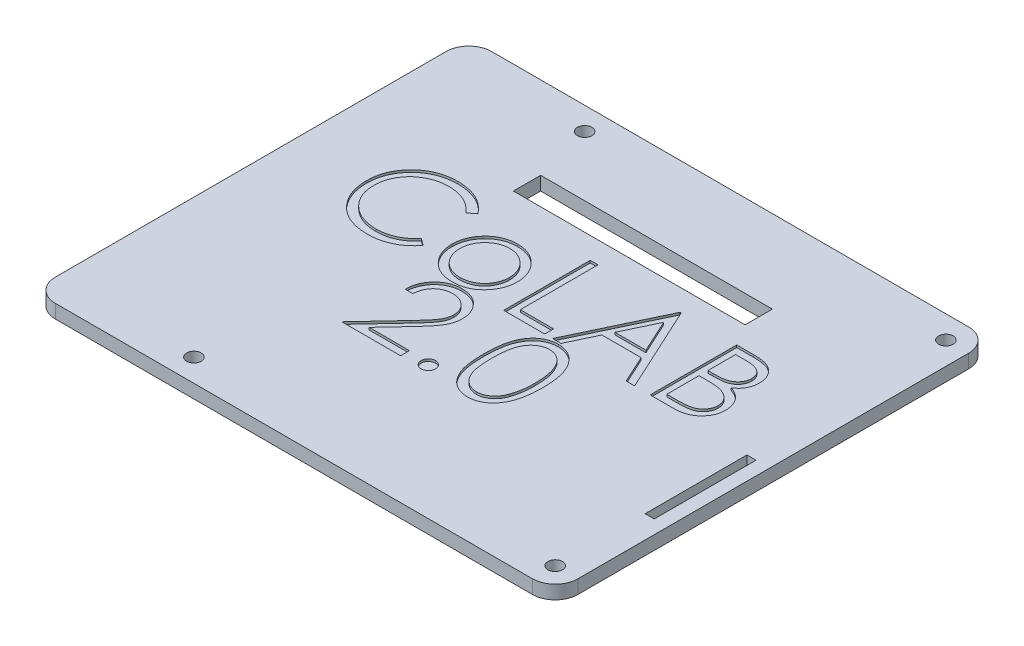
from build123d import *

# Parameters (mm, degrees)
BOSS_EXTRUDE1_DEPTH     = 3
CUT_EXTRUDE1_DEPTH      = 0.5
SKETCH3_R               = 1.6
CUT_EXTRUDE2_DEPTH      = 1
CUT_EXTRUDE2_DEPTH_BACK = 4.0000001
SKETCH5_W               = 2
SKETCH5_H               = 22.4
CUT_EXTRUDE3_DEPTH      = 1.0000001
CUT_EXTRUDE3_DEPTH_BACK = 4
SKETCH6_R               = 3.5
SKETCH6_R_2             = 1.45
BOSS_EXTRUDE2_DEPTH     = 5
SKETCH7_W               = 51
SKETCH7_H               = 6
CUT_EXTRUDE4_DEPTH      = 1.0000001
CUT_EXTRUDE4_DEPTH_BACK = 9


with BuildPart() as part:
    # Sketch1 → Boss-Extrude1 (new body)
    with BuildSketch(Plane(origin=(0, 0, 0), x_dir=(1, 0, 0), z_dir=(0, 1, 0))):
        with BuildLine():
            Line((5, 0), (110, 0))
            ThreePointArc((110, 0), (113.535533906, 1.464466094), (115, 5))
            Line((115, 5), (115, 91))
            ThreePointArc((115, 91), (113.535533906, 94.535533906), (110, 96))
            Line((110, 96), (5, 96))
            ThreePointArc((5, 96), (1.464466094, 94.535533906), (0, 91))
            Line((0, 91), (0, 5))
            ThreePointArc((0, 5), (1.464466094, 1.464466094), (5, 0))
        make_face()
    extrude(amount=BOSS_EXTRUDE1_DEPTH)

    # Sketch2 → Cut-Extrude1 (cut)
    with BuildSketch(Plane(origin=(0, 3, 0), x_dir=(1, 0, 0), z_dir=(0, 1, 0))):
        with BuildLine():
            Line((34.420192308, 63.554447115), (32.924278846, 62.409615385))
            add(Edge.make_bspline(
                [(32.924278846, 62.409615385), (32.817566797, 62.53679302), (32.605581408, 62.789433662), (32.26453632, 63.144196611), (31.909108806, 63.476566105), (31.539434732, 63.788125479), (31.148860096, 64.067979589), (30.74684632, 64.330712307), (30.326668389, 64.566212423), (29.745633947, 64.851760962), (28.985550659, 65.149736463), (28.028724463, 65.399581193), (27.02989977, 65.558627878), (26.348467121, 65.575853658), (26.001862981, 65.584615385)],
                knots=[0, 0, 0, 0, 0.00049794, 0.000989166, 0.001475147, 0.001957397, 0.002438287, 0.002915667, 0.003397525, 0.003882215, 0.004857325, 0.005840349, 0.006844209, 0.007883375, 0.007883375, 0.007883375, 0.007883375], degree=3))
            add(Edge.make_bspline(
                [(26.001862981, 65.584615385), (25.810909594, 65.582416674), (25.430775049, 65.57803966), (24.866631215, 65.520295707), (24.313021608, 65.439136121), (23.770306342, 65.318711147), (23.239176239, 65.166460178), (22.716159022, 64.984530425), (22.208827043, 64.759441939), (21.710162061, 64.51065841), (21.232392355, 64.229657604), (20.780335595, 63.923152074), (20.355640513, 63.594571707), (19.957971152, 63.24268497), (19.586920976, 62.869076586), (19.245178613, 62.469764955), (18.933926594, 62.046026696), (18.646995358, 61.603449435), (18.390023195, 61.143322312), (18.174867709, 60.663942286), (17.984339829, 60.173518525), (17.833576809, 59.666510064), (17.714244796, 59.146484438), (17.631907085, 58.612046007), (17.574819835, 58.064311265), (17.570464586, 57.693057721), (17.568269231, 57.505919471)],
                knots=[0, 0, 0, 0, 0.000572619, 0.001139924, 0.001699592, 0.002250514, 0.002806148, 0.003356514, 0.003910218, 0.00446999, 0.005027612, 0.005571644, 0.006107491, 0.006637367, 0.007163561, 0.007685922, 0.008212558, 0.008739692, 0.009267502, 0.009791769, 0.010314798, 0.010844798, 0.0113771, 0.011914141, 0.012466252, 0.013027427, 0.013027427, 0.013027427, 0.013027427], degree=3))
            add(Edge.make_bspline(
                [(17.568269231, 57.505919471), (17.575137131, 57.224353287), (17.588621343, 56.671535432), (17.708627276, 55.861798252), (17.890990702, 55.086078585), (18.164306913, 54.349225443), (18.50132346, 53.642152809), (18.927175931, 52.976824192), (19.420388799, 52.343185462), (19.987939567, 51.756211704), (20.61063408, 51.220015571), (21.278733428, 50.747844548), (21.990573622, 50.354244974), (22.738294995, 50.026715893), (23.527651415, 49.774947133), (24.357223411, 49.597705261), (25.2252067, 49.482087107), (25.818311576, 49.471018033), (26.12016226, 49.465384615)],
                knots=[0, 0, 0, 0, 0.000844222, 0.001657519, 0.002450727, 0.003230596, 0.004010586, 0.004796148, 0.005595401, 0.006415872, 0.007241219, 0.008057492, 0.008865515, 0.009677279, 0.010502758, 0.011346325, 0.012219621, 0.01312469, 0.01312469, 0.01312469, 0.01312469], degree=3))
            add(Edge.make_bspline(
                [(26.12016226, 49.465384615), (26.452735467, 49.474576402), (27.107319097, 49.492668038), (28.067265069, 49.645934808), (28.986214022, 49.894444332), (29.864215386, 50.242231595), (30.69879396, 50.694344091), (31.491255782, 51.242428252), (32.242269759, 51.891697606), (32.693870595, 52.387450061), (32.924278846, 52.640384615)],
                knots=[0, 0, 0, 0, 0.000997238, 0.001962804, 0.002907981, 0.00384834, 0.004789132, 0.005749229, 0.006733947, 0.007759692, 0.007759692, 0.007759692, 0.007759692], degree=3))
            Line((32.924278846, 52.640384615), (34.420192308, 51.507001202))
            add(Edge.make_bspline(
                [(34.420192308, 51.507001202), (34.299806595, 51.351670485), (34.059611811, 51.041753077), (33.670676033, 50.604845628), (33.260952457, 50.193887949), (32.827397807, 49.812193325), (32.374999542, 49.452124019), (31.895634527, 49.123909766), (31.395604507, 48.822969382), (30.876603701, 48.547414264), (30.339183537, 48.302936105), (29.78398797, 48.093637741), (29.213410123, 47.913343699), (28.627423913, 47.7650153), (28.024813865, 47.64923983), (27.40775457, 47.571844171), (26.774914249, 47.518820322), (26.3479688, 47.513987523), (26.131610577, 47.511538462)],
                knots=[0, 0, 0, 0, 0.000589425, 0.001176026, 0.001753482, 0.00232931, 0.002908013, 0.003487018, 0.004070795, 0.004658029, 0.005248935, 0.005840739, 0.006436956, 0.007043188, 0.007653157, 0.008276538, 0.008908147, 0.009557065, 0.009557065, 0.009557065, 0.009557065], degree=3))
            add(Edge.make_bspline(
                [(26.131610577, 47.511538462), (25.926721475, 47.51296445), (25.521578647, 47.515784164), (24.923415442, 47.561461533), (24.341086438, 47.623780815), (23.776255974, 47.717616386), (23.225841739, 47.828347722), (22.694833415, 47.976781276), (22.17800577, 48.143056026), (21.67743523, 48.338481739), (21.192696006, 48.559005533), (20.725351547, 48.808242446), (20.275616794, 49.084096595), (19.839070146, 49.380487438), (19.422160441, 49.706935324), (19.021274824, 50.058906577), (18.634165346, 50.435214893), (18.394665018, 50.706567737), (18.274248798, 50.842998798)],
                knots=[0, 0, 0, 0, 0.0006145, 0.001215097, 0.001798762, 0.002370923, 0.002932241, 0.003482144, 0.004023991, 0.004560449, 0.005093244, 0.005620764, 0.006148271, 0.006675391, 0.00720287, 0.00773561, 0.008275316, 0.008821059, 0.008821059, 0.008821059, 0.008821059], degree=3))
            add(Edge.make_bspline(
                [(18.274248798, 50.842998798), (18.081377653, 51.079987269), (17.697963872, 51.551103079), (17.207422651, 52.314659634), (16.787519529, 53.111865171), (16.448016303, 53.946907926), (16.182607713, 54.817914134), (15.998741494, 55.725322862), (15.879262047, 56.668286662), (15.865598904, 57.309655469), (15.858653846, 57.635667067)],
                knots=[0, 0, 0, 0, 0.000916064, 0.001821069, 0.002717204, 0.003615773, 0.004521164, 0.005444709, 0.006390426, 0.007368094, 0.007368094, 0.007368094, 0.007368094], degree=3))
            add(Edge.make_bspline(
                [(15.858653846, 57.635667067), (15.867118543, 57.978324607), (15.883772304, 58.652481925), (16.025263705, 59.641851585), (16.252877439, 60.589732771), (16.576166218, 61.494356009), (16.986042487, 62.360479391), (17.492373057, 63.181486521), (18.089275645, 63.962627959), (18.772068835, 64.692051105), (19.520828189, 65.359015296), (20.322663447, 65.945789062), (21.176005187, 66.434108685), (22.071452351, 66.842302083), (23.015710132, 67.156052661), (24.006763899, 67.375689291), (25.04275142, 67.512398167), (25.749574052, 67.52968037), (26.108713942, 67.538461538)],
                knots=[0, 0, 0, 0, 0.001027553, 0.002021647, 0.002991636, 0.003947584, 0.004898354, 0.00586111, 0.006835779, 0.007842891, 0.008853835, 0.009840024, 0.01081793, 0.011798246, 0.012787788, 0.013796915, 0.014839669, 0.015916785, 0.015916785, 0.015916785, 0.015916785], degree=3))
            add(Edge.make_bspline(
                [(26.108713942, 67.538461538), (26.327595568, 67.535837329), (26.760849703, 67.530642971), (27.401760569, 67.479990969), (28.025742377, 67.395552627), (28.633225008, 67.280620875), (29.227163819, 67.137978168), (29.803019415, 66.952157402), (30.36417084, 66.739687138), (30.907079011, 66.494984631), (31.429139091, 66.220301367), (31.930188482, 65.918682045), (32.406247213, 65.590500589), (32.860665088, 65.238548163), (33.285840466, 64.855378861), (33.693845084, 64.451531946), (34.070823238, 64.015374989), (34.303522771, 63.708370992), (34.420192308, 63.554447115)],
                knots=[0, 0, 0, 0, 0.000656548, 0.00129957, 0.001927235, 0.002544702, 0.003153715, 0.00375836, 0.004358654, 0.004953036, 0.005543646, 0.006127422, 0.006706428, 0.007277417, 0.007850392, 0.008422452, 0.008998633, 0.009577991, 0.009577991, 0.009577991, 0.009577991], degree=3))
        make_face()
        with BuildLine():
            add(Edge.make_bspline(
                [(44.563401442, 62.165384615), (44.824611084, 62.159822608), (45.336779356, 62.148916871), (46.086847992, 62.032358272), (46.802829375, 61.854119046), (47.48746565, 61.607712401), (48.131988629, 61.277429213), (48.745786401, 60.883315785), (49.32717612, 60.416413383), (49.675644323, 60.055235897), (49.852524038, 59.871905048)],
                knots=[0, 0, 0, 0, 0.000783055, 0.00153538, 0.002271186, 0.002994326, 0.003712818, 0.004438972, 0.005179778, 0.005943429, 0.005943429, 0.005943429, 0.005943429], degree=3))
            add(Edge.make_bspline(
                [(49.852524038, 59.871905048), (50.004825817, 59.696568925), (50.306481915, 59.349289917), (50.69328247, 58.786195795), (51.026502676, 58.203047533), (51.293545364, 57.59210137), (51.504102421, 56.958690659), (51.653594282, 56.300638284), (51.742513886, 55.619397509), (51.75450432, 55.156733762), (51.760576923, 54.922415865)],
                knots=[0, 0, 0, 0, 0.000696259, 0.001379043, 0.002045498, 0.002708457, 0.003375796, 0.004045107, 0.00473002, 0.005432847, 0.005432847, 0.005432847, 0.005432847], degree=3))
            add(Edge.make_bspline(
                [(51.760576923, 54.922415865), (51.755235644, 54.686739837), (51.744681028, 54.221033014), (51.644839345, 53.535127609), (51.48954872, 52.870038646), (51.267306858, 52.228550613), (50.982329149, 51.608702652), (50.634581264, 51.013202105), (50.221622891, 50.440874065), (49.753515423, 49.896578346), (49.23616164, 49.394930805), (48.674915175, 48.95771551), (48.080805363, 48.583129784), (47.445932254, 48.281397293), (46.776093505, 48.043491639), (46.06984432, 47.876395835), (45.328281865, 47.775367242), (44.821947989, 47.762393793), (44.563401442, 47.755769231)],
                knots=[0, 0, 0, 0, 0.000706639, 0.001396352, 0.002074825, 0.002753062, 0.003429246, 0.004118441, 0.004818465, 0.005543646, 0.006269639, 0.006976516, 0.007674289, 0.008372397, 0.009080888, 0.009802849, 0.01054601, 0.011321441, 0.011321441, 0.011321441, 0.011321441], degree=3))
            add(Edge.make_bspline(
                [(44.563401442, 47.755769231), (44.303588183, 47.762416027), (43.79473079, 47.775434114), (43.050550802, 47.876003324), (42.343035876, 48.04341463), (41.672320219, 48.282179126), (41.034717552, 48.583139428), (40.437165333, 48.956583053), (39.875462935, 49.395060469), (39.357999706, 49.896543212), (38.889921583, 50.440883117), (38.476955637, 51.013199756), (38.129209719, 51.608703264), (37.844231495, 52.228550449), (37.62198977, 52.870038689), (37.466699109, 53.535127597), (37.366857435, 54.221033017), (37.356302818, 54.686739838), (37.350961538, 54.922415865)],
                knots=[0, 0, 0, 0, 0.000779243, 0.001526186, 0.002248147, 0.002956639, 0.00365819, 0.004359201, 0.005066078, 0.005792071, 0.006517252, 0.007217276, 0.007906471, 0.008582655, 0.009260891, 0.009939365, 0.010629078, 0.011335717, 0.011335717, 0.011335717, 0.011335717], degree=3))
            add(Edge.make_bspline(
                [(37.350961538, 54.922415865), (37.357075556, 55.155460208), (37.369180261, 55.616847955), (37.45801046, 56.2968081), (37.606919175, 56.953746746), (37.817728633, 57.584712551), (38.087232743, 58.192981424), (38.41577061, 58.777570576), (38.806516767, 59.338118461), (39.106973103, 59.68494864), (39.259014423, 59.860456731)],
                knots=[0, 0, 0, 0, 0.000699014, 0.001383928, 0.002053239, 0.002716956, 0.003376425, 0.004046203, 0.004725856, 0.005422115, 0.005422115, 0.005422115, 0.005422115], degree=3))
            add(Edge.make_bspline(
                [(39.259014423, 59.860456731), (39.435627469, 60.045377472), (39.782968099, 60.409056647), (40.367251888, 60.874597956), (40.979539686, 61.276912587), (41.631185356, 61.600633131), (42.315259197, 61.855568492), (43.034909645, 62.032817938), (43.787523522, 62.148496913), (44.302198031, 62.159699281), (44.563401442, 62.165384615)],
                knots=[0, 0, 0, 0, 0.000766344, 0.00150715, 0.002235377, 0.002960688, 0.003685145, 0.004420951, 0.005180826, 0.005963881, 0.005963881, 0.005963881, 0.005963881], degree=3))
        make_face()
        with BuildLine():
            add(Edge.make_bspline(
                [(44.555769231, 60.455769231), (44.371051661, 60.450519096), (44.006384975, 60.440154358), (43.469612663, 60.361320534), (42.952866969, 60.236420547), (42.455167517, 60.058961327), (41.978192678, 59.829823034), (41.521485788, 59.548381817), (41.083703508, 59.218365296), (40.673409706, 58.840289898), (40.296860264, 58.427291371), (39.967687277, 57.987245303), (39.68778777, 57.527289333), (39.454614905, 57.046945155), (39.280948638, 56.541345016), (39.154821187, 56.016214723), (39.076061735, 55.470484385), (39.065794446, 55.0994937), (39.060576923, 54.910967548)],
                knots=[0, 0, 0, 0, 0.00055398, 0.001093659, 0.001624001, 0.002146641, 0.00267576, 0.003208513, 0.003753455, 0.004317942, 0.004879857, 0.00542785, 0.00596386, 0.006492979, 0.007026416, 0.007564175, 0.008111411, 0.008676826, 0.008676826, 0.008676826, 0.008676826], degree=3))
            add(Edge.make_bspline(
                [(39.060576923, 54.910967548), (39.069322635, 54.667388657), (39.086681237, 54.183930107), (39.227843023, 53.471943854), (39.463988347, 52.788419773), (39.782870541, 52.137364872), (40.182410102, 51.534991473), (40.653146851, 50.99793668), (41.190028649, 50.534282477), (41.7866556, 50.149576732), (42.430841244, 49.843907205), (43.112593506, 49.627287066), (43.823652141, 49.48647114), (44.309594406, 49.472474972), (44.555769231, 49.465384615)],
                knots=[0, 0, 0, 0, 0.000730313, 0.001449535, 0.002167582, 0.002894618, 0.003618562, 0.004329721, 0.005030483, 0.005739673, 0.006453204, 0.007162815, 0.007881317, 0.008619021, 0.008619021, 0.008619021, 0.008619021], degree=3))
            add(Edge.make_bspline(
                [(44.555769231, 49.465384615), (44.801929896, 49.472516284), (45.287844211, 49.486593999), (45.997914874, 49.62657786), (46.677803778, 49.844856357), (47.32132033, 50.149232956), (47.9176757, 50.535743385), (48.458418775, 50.995318523), (48.925136215, 51.536413914), (49.32428055, 52.138162749), (49.648384964, 52.787410437), (49.883424963, 53.472070008), (50.024926109, 54.183897979), (50.042238905, 54.667377893), (50.050961538, 54.910967548)],
                knots=[0, 0, 0, 0, 0.000737704, 0.001456207, 0.002162186, 0.002875716, 0.003584906, 0.004288562, 0.004997207, 0.005721152, 0.006449878, 0.007167925, 0.007887147, 0.00861746, 0.00861746, 0.00861746, 0.00861746], degree=3))
            add(Edge.make_bspline(
                [(50.050961538, 54.910967548), (50.045745812, 55.099494826), (50.035482057, 55.470487729), (49.956696894, 56.016201941), (49.8306646, 56.541391917), (49.656647654, 57.046772106), (49.42448795, 57.528533022), (49.139190834, 57.985894822), (48.811361967, 58.428815737), (48.43026878, 58.838954839), (48.020403252, 59.218512681), (47.582443544, 59.548509786), (47.126413875, 59.828586128), (46.650824732, 60.060921237), (46.153061471, 60.234806047), (45.637039811, 60.362041712), (45.102557717, 60.439821211), (44.739197782, 60.450419224), (44.555769231, 60.455769231)],
                knots=[0, 0, 0, 0, 0.000565415, 0.00111265, 0.00165041, 0.002183846, 0.002712966, 0.003250969, 0.003798962, 0.004363449, 0.004927936, 0.005472878, 0.006005632, 0.006531314, 0.007057549, 0.007584185, 0.008123864, 0.008674032, 0.008674032, 0.008674032, 0.008674032], degree=3))
        make_face(mode=Mode.SUBTRACT)
        Polygon((55.668269231, 67.05), (57.377884615, 67.05), (57.377884615, 49.953846154), (64.704807692, 49.953846154), (64.704807692, 48), (55.668269231, 48), align=None)
        Polygon((75.695192308, 67.05), (84.4875, 48), (82.62905649, 48), (79.812770433, 54.105769231), (71.176923077, 54.105769231), (68.280498798, 48), (66.414423077, 48), (75.450961538, 67.05), align=None)
        Polygon((75.553996394, 63.336929087), (72.104236779, 56.059615385), (78.912169471, 56.059615385), align=None, mode=Mode.SUBTRACT)
        with BuildLine():
            Line((87.906730769, 67.05), (91.623617788, 67.05))
            add(Edge.make_bspline(
                [(91.623617788, 67.05), (91.80556422, 67.049043416), (92.158221686, 67.047189317), (92.671044648, 67.018433989), (93.151370317, 66.979225443), (93.599337993, 66.917013082), (94.014740673, 66.841946409), (94.398830241, 66.75104081), (94.750385322, 66.642038813), (95.17009893, 66.468704053), (95.648638527, 66.211130809), (96.166789778, 65.830519618), (96.609861424, 65.36497864), (96.991875522, 64.83983733), (97.295593045, 64.262155487), (97.515317363, 63.645701902), (97.654425227, 62.99842785), (97.668731419, 62.554055696), (97.675961538, 62.329477163)],
                knots=[0, 0, 0, 0, 0.000545756, 0.001057812, 0.00154047, 0.00199111, 0.00241401, 0.002806457, 0.003174568, 0.003516849, 0.004167392, 0.004800106, 0.005437019, 0.006087371, 0.006742853, 0.007387425, 0.008046032, 0.008718977, 0.008718977, 0.008718977, 0.008718977], degree=3))
            add(Edge.make_bspline(
                [(97.675961538, 62.329477163), (97.670011307, 62.119096825), (97.65831854, 61.705679619), (97.546507236, 61.101010253), (97.371461312, 60.525421476), (97.128137027, 59.981013921), (96.811896162, 59.480088113), (96.43711017, 59.018603136), (95.984935003, 58.616098097), (95.646153939, 58.391074585), (95.47406851, 58.276772837)],
                knots=[0, 0, 0, 0, 0.000630593, 0.001239176, 0.001837903, 0.002432285, 0.003022056, 0.003610343, 0.004210261, 0.004829576, 0.004829576, 0.004829576, 0.004829576], degree=3))
            add(Edge.make_bspline(
                [(95.47406851, 58.276772837), (95.690478837, 58.193687628), (96.104525402, 58.034725042), (96.674316412, 57.753680588), (97.165234069, 57.447998245), (97.581052821, 57.114177746), (97.936676342, 56.754356933), (98.247207353, 56.363259811), (98.512173118, 55.935784572), (98.739210602, 55.476388187), (98.916368831, 54.989761552), (99.049043396, 54.480469185), (99.125066227, 53.95033732), (99.135884674, 53.589555469), (99.141346154, 53.407421875)],
                knots=[0, 0, 0, 0, 0.00069517, 0.001330033, 0.001902818, 0.002426682, 0.002925892, 0.003417578, 0.003921593, 0.004431882, 0.004952231, 0.005472399, 0.0060083, 0.006554657, 0.006554657, 0.006554657, 0.006554657], degree=3))
            add(Edge.make_bspline(
                [(99.141346154, 53.407421875), (99.13602932, 53.221456471), (99.125568302, 52.855564329), (99.048388741, 52.318054239), (98.917710602, 51.804384887), (98.737709076, 51.311233821), (98.502782764, 50.839555089), (98.216880558, 50.388814324), (97.875985905, 49.963540324), (97.494643718, 49.559007461), (97.063231183, 49.195273362), (96.597781146, 48.871337873), (96.09243189, 48.604931449), (95.55548318, 48.381142817), (94.980911688, 48.210197923), (94.371297497, 48.090604342), (93.727166368, 48.010022641), (93.285153294, 48.003397568), (93.058473558, 48)],
                knots=[0, 0, 0, 0, 0.000557791, 0.00109747, 0.001625032, 0.002145382, 0.002669315, 0.003202874, 0.00374343, 0.00430216, 0.004867987, 0.005433235, 0.006000039, 0.006578327, 0.007175946, 0.007794874, 0.008440506, 0.009120159, 0.009120159, 0.009120159, 0.009120159], degree=3))
            Line((93.058473558, 48), (87.906730769, 48))
            Line((87.906730769, 48), (87.906730769, 67.05))
        make_face()
        with BuildLine():
            Line((89.616346154, 65.096153846), (89.616346154, 58.990384615))
            Line((89.616346154, 58.990384615), (90.76499399, 58.990384615))
            add(Edge.make_bspline(
                [(90.76499399, 58.990384615), (90.932899577, 58.992561339), (91.257327386, 58.996767213), (91.727154252, 59.00881507), (92.163263279, 59.042550135), (92.564901685, 59.076275504), (92.931436987, 59.131110046), (93.262057148, 59.196381458), (93.56195094, 59.265412698), (93.907787609, 59.382812334), (94.300070371, 59.556317966), (94.718261981, 59.825586103), (95.086931023, 60.146302939), (95.398247144, 60.516368031), (95.653035291, 60.923853986), (95.830002798, 61.362259149), (95.950003016, 61.820657296), (95.960842637, 62.135353787), (95.966346154, 62.295132212)],
                knots=[0, 0, 0, 0, 0.000503784, 0.000973413, 0.001409519, 0.001815822, 0.002182268, 0.002520548, 0.002826908, 0.003104462, 0.003615151, 0.004109495, 0.004590899, 0.005075605, 0.005555358, 0.006025916, 0.006489616, 0.006967864, 0.006967864, 0.006967864, 0.006967864], degree=3))
            add(Edge.make_bspline(
                [(95.966346154, 62.295132212), (95.96348223, 62.400863911), (95.957864331, 62.608268185), (95.911854213, 62.910615384), (95.833653558, 63.194970665), (95.733209476, 63.465230894), (95.592845327, 63.712945393), (95.427581334, 63.946679073), (95.227906363, 64.158472175), (95.000627275, 64.356426159), (94.7393232, 64.531928517), (94.444150026, 64.685638957), (94.11111424, 64.809413755), (93.745828558, 64.917814528), (93.342670211, 64.993950813), (92.90629157, 65.057378537), (92.433118314, 65.089669604), (92.105757113, 65.093944222), (91.936538462, 65.096153846)],
                knots=[0, 0, 0, 0, 0.000317104, 0.000622035, 0.000914559, 0.001200868, 0.001484418, 0.001766113, 0.002057739, 0.002355347, 0.002668639, 0.002999762, 0.003351279, 0.00373289, 0.004141516, 0.004580816, 0.005055258, 0.005562929, 0.005562929, 0.005562929, 0.005562929], degree=3))
            Line((91.936538462, 65.096153846), (89.616346154, 65.096153846))
        make_face(mode=Mode.SUBTRACT)
        with BuildLine():
            Line((89.616346154, 57.036538462), (89.616346154, 49.953846154))
            Line((89.616346154, 49.953846154), (92.051021635, 49.953846154))
            add(Edge.make_bspline(
                [(92.051021635, 49.953846154), (92.225296074, 49.955934836), (92.561187082, 49.959960496), (93.046152348, 49.973102571), (93.495640385, 50.002996243), (93.907600095, 50.050054368), (94.286479844, 50.101099927), (94.627734485, 50.169741327), (94.934130295, 50.248384955), (95.289409027, 50.369946664), (95.689478122, 50.558794599), (96.120611498, 50.84353346), (96.503931342, 51.182750321), (96.829442825, 51.575348582), (97.096213519, 52.00223909), (97.290281068, 52.454787352), (97.409974159, 52.925515723), (97.424463967, 53.246463115), (97.431730769, 53.407421875)],
                knots=[0, 0, 0, 0, 0.000522862, 0.001007748, 0.001455275, 0.001873744, 0.002251519, 0.00260177, 0.002917401, 0.003199793, 0.003727272, 0.004239541, 0.004745013, 0.005257068, 0.005764323, 0.006249869, 0.006729304, 0.007211645, 0.007211645, 0.007211645, 0.007211645], degree=3))
            add(Edge.make_bspline(
                [(97.431730769, 53.407421875), (97.430227973, 53.508078486), (97.42724662, 53.707768106), (97.382285273, 54.001224208), (97.316895496, 54.285482176), (97.23236012, 54.561313877), (97.109245592, 54.823732397), (96.96551854, 55.077927757), (96.797000054, 55.324235981), (96.534413951, 55.635634103), (96.152477864, 55.994410988), (95.609788129, 56.345679393), (94.992718907, 56.628968171), (94.54516641, 56.749252464), (94.313972356, 56.811388221)],
                knots=[0, 0, 0, 0, 0.00030169, 0.000598513, 0.000888261, 0.001176699, 0.001461887, 0.001755827, 0.002052208, 0.00235563, 0.002976636, 0.003615922, 0.004287047, 0.005004191, 0.005004191, 0.005004191, 0.005004191], degree=3))
            add(Edge.make_bspline(
                [(94.313972356, 56.811388221), (94.22128542, 56.83019375), (94.020321024, 56.870968014), (93.692619765, 56.914008514), (93.31850025, 56.952353768), (92.89709859, 56.980717355), (92.427881626, 57.010035542), (91.909847254, 57.021437354), (91.345111013, 57.03504047), (90.953266815, 57.036026358), (90.749729567, 57.036538462)],
                knots=[0, 0, 0, 0, 0.000283652, 0.000615017, 0.000990937, 0.001411818, 0.001881958, 0.002401173, 0.002966073, 0.003576662, 0.003576662, 0.003576662, 0.003576662], degree=3))
            Line((90.749729567, 57.036538462), (89.616346154, 57.036538462))
        make_face(mode=Mode.SUBTRACT)
        with BuildLine():
            Line((42.479807692, 41.188461538), (40.770192308, 41.188461538))
            add(Edge.make_bspline(
                [(40.770192308, 41.188461538), (40.781334669, 41.415270228), (40.80321797, 41.860716457), (40.905697659, 42.510179433), (41.052333005, 43.130963409), (41.259659347, 43.718083941), (41.517140659, 44.276732306), (41.825914094, 44.804689534), (42.191640623, 45.299941576), (42.60642299, 45.75789728), (43.056920868, 46.178018201), (43.543000339, 46.540813165), (44.053785416, 46.847342205), (44.58772643, 47.103598679), (45.150847498, 47.295948411), (45.738038481, 47.43866905), (46.351879209, 47.524537446), (46.770108472, 47.533767365), (46.9828125, 47.538461538)],
                knots=[0, 0, 0, 0, 0.000680809, 0.00133709, 0.001969252, 0.002592014, 0.003201565, 0.003812201, 0.004423565, 0.00504504, 0.005663449, 0.006268684, 0.006860967, 0.007448164, 0.008041934, 0.008642628, 0.00925895, 0.009896799, 0.009896799, 0.009896799, 0.009896799], degree=3))
            add(Edge.make_bspline(
                [(46.9828125, 47.538461538), (47.191698875, 47.533571368), (47.602153139, 47.523962359), (48.201204961, 47.441443042), (48.771492806, 47.312199179), (49.311901935, 47.130868128), (49.818120658, 46.887112887), (50.293951801, 46.59430057), (50.745060214, 46.255646916), (51.151134279, 45.856936874), (51.524013967, 45.431292467), (51.845699099, 44.976879735), (52.121179317, 44.507546051), (52.350800832, 44.019712554), (52.51983496, 43.508785956), (52.648167778, 42.982204753), (52.720706987, 42.434518281), (52.731839934, 42.063824029), (52.7375, 41.875360577)],
                knots=[0, 0, 0, 0, 0.000626411, 0.001230876, 0.001810371, 0.002378766, 0.002936923, 0.003491927, 0.004052907, 0.004625069, 0.005195867, 0.00574861, 0.006292495, 0.006826886, 0.007362692, 0.007904163, 0.008450879, 0.009016294, 0.009016294, 0.009016294, 0.009016294], degree=3))
            add(Edge.make_bspline(
                [(52.7375, 41.875360577), (52.728283812, 41.610033077), (52.710013168, 41.0840342), (52.553724918, 40.31106759), (52.309631765, 39.562166266), (52.015731865, 38.95943895), (51.719246134, 38.473753792), (51.452069843, 38.073874126), (51.139297086, 37.643314363), (50.776375547, 37.183516283), (50.370812628, 36.690878357), (49.918934853, 36.165698185), (49.417519901, 35.613401838), (49.065592919, 35.23618135), (48.883233173, 35.040715144)],
                knots=[0, 0, 0, 0, 0.000795299, 0.001576641, 0.002356211, 0.003153266, 0.003581282, 0.004062853, 0.004595648, 0.00517735, 0.005819874, 0.006509872, 0.007255587, 0.008057559, 0.008057559, 0.008057559, 0.008057559], degree=3))
            Line((48.883233173, 35.040715144), (44.116917067, 29.953846154))
            Line((44.116917067, 29.953846154), (52.981730769, 29.953846154))
            Line((52.981730769, 29.953846154), (52.981730769, 28))
            Line((52.981730769, 28), (40.0375, 28))
            Line((40.0375, 28), (47.425480769, 35.884074519))
            add(Edge.make_bspline(
                [(47.425480769, 35.884074519), (47.605355696, 36.071843873), (47.950858618, 36.432510375), (48.439532357, 36.959068486), (48.878438851, 37.447562415), (49.270419232, 37.8970692), (49.606970168, 38.314163877), (49.905631888, 38.685337906), (50.144930318, 39.026901414), (50.404638401, 39.422818184), (50.656174499, 39.906210939), (50.87232318, 40.496944305), (51.004121141, 41.10505978), (51.019931746, 41.516006582), (51.027884615, 41.722716346)],
                knots=[0, 0, 0, 0, 0.000780065, 0.001498345, 0.002154992, 0.002750207, 0.003287207, 0.003762814, 0.004178927, 0.004537763, 0.005182945, 0.005808274, 0.006420494, 0.007040127, 0.007040127, 0.007040127, 0.007040127], degree=3))
            add(Edge.make_bspline(
                [(51.027884615, 41.722716346), (51.024424361, 41.852699386), (51.017604864, 42.108870997), (50.957419396, 42.484459486), (50.866466498, 42.846762258), (50.73613588, 43.196893742), (50.564104909, 43.531333648), (50.354699798, 43.850489076), (50.113091024, 44.159039015), (49.833593401, 44.448344823), (49.526553558, 44.71330967), (49.202190571, 44.948027907), (48.85901786, 45.144183638), (48.498482338, 45.304984673), (48.12158914, 45.431124962), (47.727609313, 45.518529516), (47.317631453, 45.573407036), (47.037686284, 45.580832028), (46.895042067, 45.584615385)],
                knots=[0, 0, 0, 0, 0.00038971, 0.000768044, 0.001138265, 0.001508978, 0.001886155, 0.002264027, 0.002652614, 0.003060152, 0.003468689, 0.003867942, 0.004259386, 0.004652278, 0.005050509, 0.005449524, 0.005861328, 0.006289158, 0.006289158, 0.006289158, 0.006289158], degree=3))
            add(Edge.make_bspline(
                [(46.895042067, 45.584615385), (46.746066535, 45.580723566), (46.453503187, 45.573080677), (46.023958165, 45.51961732), (45.614188433, 45.427383532), (45.223163218, 45.301236204), (44.850220901, 45.140897531), (44.497175176, 44.941189607), (44.164818593, 44.702882308), (43.852526373, 44.432695852), (43.564795287, 44.131882194), (43.311991577, 43.796547966), (43.091098585, 43.432815891), (42.898371186, 43.041667409), (42.741858073, 42.619553263), (42.622261354, 42.167971898), (42.527627231, 41.688884094), (42.496012283, 41.35803956), (42.479807692, 41.188461538)],
                knots=[0, 0, 0, 0, 0.000446892, 0.000877622, 0.001296091, 0.001705198, 0.002108569, 0.002511851, 0.002919531, 0.003333451, 0.003749144, 0.004165869, 0.004590624, 0.005024118, 0.0054721, 0.005938665, 0.006424391, 0.006935151, 0.006935151, 0.006935151, 0.006935151], degree=3))
        make_face()
        with BuildLine():
            add(Edge.make_bspline(
                [(57.744230769, 30.930769231), (57.85031321, 30.924465495), (58.058275433, 30.912107758), (58.358934117, 30.827326148), (58.631047907, 30.67678401), (58.873430554, 30.476145174), (59.073218662, 30.232873064), (59.229125779, 29.962929618), (59.313168855, 29.659753807), (59.325436575, 29.450586576), (59.331730769, 29.343269231)],
                knots=[0, 0, 0, 0, 0.000318205, 0.000623803, 0.000927753, 0.001244857, 0.001561962, 0.001867751, 0.002173349, 0.002495352, 0.002495352, 0.002495352, 0.002495352], degree=3))
            add(Edge.make_bspline(
                [(59.331730769, 29.343269231), (59.325223285, 29.238530536), (59.312390622, 29.031987368), (59.229318427, 28.731098264), (59.072030467, 28.460986113), (58.874808577, 28.214413047), (58.630987989, 28.013349165), (58.358290796, 27.864087817), (58.058981234, 27.773235755), (57.85043096, 27.761662624), (57.744230769, 27.755769231)],
                knots=[0, 0, 0, 0, 0.000314406, 0.000620005, 0.000925794, 0.001245846, 0.001562951, 0.001866901, 0.002173569, 0.002491774, 0.002491774, 0.002491774, 0.002491774], degree=3))
            add(Edge.make_bspline(
                [(57.744230769, 27.755769231), (57.637954054, 27.761449381), (57.430474067, 27.772538522), (57.132281727, 27.865953225), (56.857923798, 28.011949487), (56.614150682, 28.214787952), (56.415277001, 28.459717304), (56.264915988, 28.73295851), (56.174618177, 29.031126048), (56.162742556, 29.23836089), (56.156730769, 29.343269231)],
                knots=[0, 0, 0, 0, 0.000318205, 0.000621219, 0.000928528, 0.001245632, 0.001565685, 0.001869635, 0.002176304, 0.00249071, 0.00249071, 0.00249071, 0.00249071], degree=3))
            add(Edge.make_bspline(
                [(56.156730769, 29.343269231), (56.162511624, 29.450762283), (56.173798033, 29.660629275), (56.265105555, 29.961070131), (56.414110365, 30.234129779), (56.615525444, 30.475774022), (56.857864826, 30.678179198), (57.131619885, 30.825489001), (57.431192241, 30.912794673), (57.638074905, 30.9246738), (57.744230769, 30.930769231)],
                knots=[0, 0, 0, 0, 0.000322003, 0.000628672, 0.000932622, 0.001249726, 0.001566831, 0.00187414, 0.002176071, 0.002494275, 0.002494275, 0.002494275, 0.002494275], degree=3))
        make_face()
        with BuildLine():
            add(Edge.make_bspline(
                [(61.774038462, 37.517367788), (61.775823818, 37.822697856), (61.779291897, 38.415805913), (61.81787316, 39.280048036), (61.881964666, 40.090817609), (61.969798081, 40.84815344), (62.076684802, 41.552251044), (62.21937195, 42.201228794), (62.381638776, 42.798090367), (62.569702802, 43.344782088), (62.781907768, 43.8486693), (63.012871387, 44.319069324), (63.271759769, 44.755270413), (63.543776966, 45.164234672), (63.839934099, 45.53926764), (64.15180323, 45.88566556), (64.491556585, 46.195422645), (64.847644673, 46.477614662), (65.223291429, 46.724989644), (65.607789369, 46.942882121), (66.003785017, 47.129027113), (66.412359526, 47.275387914), (66.829840591, 47.39627838), (67.257687626, 47.478949652), (67.69660705, 47.530966539), (67.992869573, 47.535939502), (68.14311899, 47.538461538)],
                knots=[0, 0, 0, 0, 0.000915937, 0.001779221, 0.002594636, 0.003355306, 0.004066137, 0.004730062, 0.005347576, 0.005920818, 0.006463001, 0.006986934, 0.007491541, 0.0079837, 0.008459307, 0.008923933, 0.009380352, 0.009836884, 0.010285645, 0.010728215, 0.01116186, 0.01159646, 0.012028911, 0.012464482, 0.012902338, 0.013352897, 0.013352897, 0.013352897, 0.013352897], degree=3))
            add(Edge.make_bspline(
                [(68.14311899, 47.538461538), (68.294623523, 47.53580643), (68.595918372, 47.530526255), (69.041363843, 47.479777368), (69.476518539, 47.395570255), (69.899527265, 47.276257522), (70.313864692, 47.128235339), (70.716289996, 46.94270403), (71.109302826, 46.726737624), (71.486657677, 46.47297052), (71.852497226, 46.190038417), (72.197835424, 45.870201605), (72.522703706, 45.516689562), (72.831179297, 45.13328456), (73.114510476, 44.712632884), (73.384331586, 44.2620508), (73.625842238, 43.773658522), (73.85844097, 43.255604832), (74.05921157, 42.69355549), (74.24027499, 42.090678722), (74.386573376, 41.439853505), (74.508434987, 40.744494512), (74.602840778, 40.002048068), (74.671598444, 39.214105693), (74.707919093, 38.380148996), (74.714759138, 37.809966988), (74.718269231, 37.517367788)],
                knots=[0, 0, 0, 0, 0.000454373, 0.000903605, 0.001342922, 0.001782718, 0.002220906, 0.002661481, 0.003110713, 0.003564765, 0.004024301, 0.004496898, 0.004974887, 0.005463587, 0.005971645, 0.006495217, 0.007037923, 0.007605177, 0.008197903, 0.008826959, 0.009492549, 0.010197734, 0.01094418, 0.011737095, 0.012569881, 0.013447718, 0.013447718, 0.013447718, 0.013447718], degree=3))
            add(Edge.make_bspline(
                [(74.718269231, 37.517367788), (74.714722749, 37.226044804), (74.707812574, 36.658413849), (74.672005613, 35.82820954), (74.601473635, 35.044448762), (74.513244984, 34.305251816), (74.3910476, 33.613695348), (74.240796624, 32.967386278), (74.073971295, 32.363533545), (73.868041916, 31.807084071), (73.642649335, 31.290275408), (73.397420339, 30.807672786), (73.134694571, 30.355010536), (72.848461545, 29.935911913), (72.543370825, 29.54740808), (72.212892574, 29.196356734), (71.866342675, 28.874299219), (71.499426526, 28.587723933), (71.116186512, 28.336890924), (70.724523536, 28.112569824), (70.317488264, 27.931689013), (69.904304907, 27.776376861), (69.479063371, 27.657720116), (69.04229373, 27.575675274), (68.596217646, 27.518134213), (68.294674842, 27.513744658), (68.14311899, 27.511538462)],
                knots=[0, 0, 0, 0, 0.000874022, 0.001702995, 0.002492108, 0.003234289, 0.003935716, 0.004597588, 0.00522451, 0.005813651, 0.006375876, 0.006915177, 0.007436812, 0.00794487, 0.008436556, 0.008917143, 0.00938974, 0.009854632, 0.010311864, 0.010762956, 0.011207004, 0.011646503, 0.0120863, 0.012529363, 0.012979032, 0.013433405, 0.013433405, 0.013433405, 0.013433405], degree=3))
            add(Edge.make_bspline(
                [(68.14311899, 27.511538462), (67.992873741, 27.514076768), (67.696619437, 27.519081812), (67.257639807, 27.570863693), (66.83155965, 27.654114932), (66.416276432, 27.770682449), (66.009659543, 27.913366058), (65.617249754, 28.099259679), (65.234683933, 28.313349397), (64.862982749, 28.557164476), (64.509130844, 28.836501066), (64.171137007, 29.14546098), (63.85749226, 29.491754119), (63.565569539, 29.869912529), (63.288124859, 30.276457176), (63.032912699, 30.71693875), (62.796851336, 31.189610672), (62.58107748, 31.697526729), (62.389768325, 32.248098551), (62.220780085, 32.847624794), (62.087353028, 33.501397042), (61.9731458, 34.204164426), (61.881028801, 34.958946818), (61.818140259, 35.766153982), (61.779271101, 36.625282905), (61.775814504, 37.21457982), (61.774038462, 37.517367788)],
                knots=[0, 0, 0, 0, 0.000450559, 0.000888415, 0.001323986, 0.00175173, 0.002181445, 0.00261509, 0.003052463, 0.003495936, 0.003947109, 0.004403529, 0.004868154, 0.005346767, 0.005835765, 0.006343666, 0.006872716, 0.007419899, 0.007997998, 0.00862021, 0.009287069, 0.009998504, 0.010755835, 0.011567446, 0.012426918, 0.013335223, 0.013335223, 0.013335223, 0.013335223], degree=3))
        make_face()
        with BuildLine():
            add(Edge.make_bspline(
                [(63.483653846, 37.525), (63.484303979, 37.270553511), (63.485565761, 36.776722838), (63.518528795, 36.059118804), (63.563433629, 35.389808871), (63.62135269, 34.767943194), (63.707365881, 34.195626697), (63.803741398, 33.668923137), (63.921024571, 33.190619889), (64.059790311, 32.757434805), (64.217845967, 32.362016304), (64.390416454, 31.994072547), (64.575804103, 31.649257007), (64.783281193, 31.330666939), (65.009241752, 31.037263389), (65.248581919, 30.763853258), (65.510234128, 30.520029689), (65.872204498, 30.227602092), (66.350068166, 29.925419378), (66.952159501, 29.662278518), (67.570840641, 29.496911148), (67.990763874, 29.475881276), (68.200360577, 29.465384615)],
                knots=[0, 0, 0, 0, 0.000763259, 0.001481336, 0.00215453, 0.002775747, 0.003354287, 0.003890175, 0.004381638, 0.004830579, 0.005253633, 0.00565823, 0.006049283, 0.006427155, 0.006797337, 0.007159566, 0.007515917, 0.007868737, 0.008554787, 0.009204198, 0.009834503, 0.01046262, 0.01046262, 0.01046262, 0.01046262], degree=3))
            add(Edge.make_bspline(
                [(68.200360577, 29.465384615), (68.411313047, 29.474081108), (68.832782449, 29.491456138), (69.448553534, 29.659089266), (70.046344004, 29.912016331), (70.514821279, 30.211087753), (70.871233408, 30.495903375), (71.126595883, 30.738734532), (71.360976461, 31.010637182), (71.58327404, 31.304003349), (71.787158438, 31.62443787), (71.97255923, 31.970399887), (72.14174145, 32.342850127), (72.238129257, 32.602853993), (72.287409856, 32.73578726)],
                knots=[0, 0, 0, 0, 0.000631609, 0.001261913, 0.001901291, 0.002573586, 0.00292104, 0.003269227, 0.003628935, 0.003996808, 0.004372612, 0.004767021, 0.005173485, 0.005598703, 0.005598703, 0.005598703, 0.005598703], degree=3))
            add(Edge.make_bspline(
                [(72.287409856, 32.73578726), (72.34484162, 32.90576627), (72.461452733, 33.250896558), (72.611739676, 33.786275865), (72.730096777, 34.347993766), (72.836577382, 34.932693329), (72.909256158, 35.544686559), (72.96775497, 36.182079877), (73.002211995, 36.845353863), (73.006483283, 37.295995172), (73.008653846, 37.525)],
                knots=[0, 0, 0, 0, 0.00053822, 0.001092817, 0.001666922, 0.002259808, 0.002875136, 0.003514992, 0.004179882, 0.004866876, 0.004866876, 0.004866876, 0.004866876], degree=3))
            add(Edge.make_bspline(
                [(73.008653846, 37.525), (73.005659245, 37.753967788), (72.999801164, 38.201877727), (72.977409317, 38.857840968), (72.919586719, 39.480872638), (72.8553658, 40.073656782), (72.760675211, 40.632912001), (72.658579148, 41.163320091), (72.52141255, 41.658309983), (72.37489206, 42.125631421), (72.207195479, 42.559974983), (72.022596982, 42.963365735), (71.825447124, 43.337751165), (71.611312929, 43.68210409), (71.382736426, 43.997966931), (71.133684622, 44.279006652), (70.874036536, 44.533933579), (70.510360139, 44.824922705), (70.034250076, 45.121622076), (69.441818767, 45.394667141), (68.825302832, 45.551466562), (68.40852446, 45.573573744), (68.200360577, 45.584615385)],
                knots=[0, 0, 0, 0, 0.000686994, 0.001343908, 0.001968223, 0.002563695, 0.00313209, 0.003669443, 0.004183202, 0.004671976, 0.005138291, 0.005578866, 0.00600223, 0.006406737, 0.00679448, 0.007170343, 0.007531968, 0.007884787, 0.008565575, 0.009209547, 0.009835214, 0.01045953, 0.01045953, 0.01045953, 0.01045953], degree=3))
            add(Edge.make_bspline(
                [(68.200360577, 45.584615385), (67.989664354, 45.573558511), (67.567888071, 45.55142462), (66.944964203, 45.39525134), (66.347859089, 45.123037911), (65.873008041, 44.823939998), (65.509078003, 44.539070046), (65.252813629, 44.29203806), (65.01253232, 44.02182059), (64.791183838, 43.725718739), (64.583869311, 43.407500097), (64.393472657, 43.064661249), (64.221928334, 42.695464823), (64.063625359, 42.300223939), (63.924436327, 41.867076227), (63.809624898, 41.389362134), (63.703559652, 40.864333837), (63.628473974, 40.288917658), (63.561724103, 39.666896223), (63.518827052, 38.995915391), (63.485455494, 38.277107835), (63.484266424, 37.780723844), (63.483653846, 37.525)],
                knots=[0, 0, 0, 0, 0.00063192, 0.001264991, 0.001912448, 0.002593236, 0.002943674, 0.003297256, 0.003659485, 0.004027358, 0.00440523, 0.004798122, 0.005202719, 0.005625774, 0.006074714, 0.006566177, 0.00709904, 0.007680818, 0.008306217, 0.008975604, 0.009697493, 0.010464569, 0.010464569, 0.010464569, 0.010464569], degree=3))
        make_face(mode=Mode.SUBTRACT)
    extrude(amount=-CUT_EXTRUDE1_DEPTH, mode=Mode.SUBTRACT)

    # Sketch3 → Cut-Extrude2 (cut, two sides)
    with BuildSketch(Plane.XZ) as cut_extrude2_sk:
        with Locations((30.5, -91)):
            Circle(SKETCH3_R)
        with Locations((110, -91)):
            Circle(SKETCH3_R)
        with Locations((110, -5)):
            Circle(SKETCH3_R)
        with Locations((30.5, -5)):
            Circle(SKETCH3_R)
    extrude(amount=CUT_EXTRUDE2_DEPTH, mode=Mode.SUBTRACT)
    extrude(cut_extrude2_sk.sketch, amount=-CUT_EXTRUDE2_DEPTH_BACK, mode=Mode.SUBTRACT)

    # Sketch5 → Cut-Extrude3 (cut, two sides)
    with BuildSketch(Plane(origin=(0, 3, 0), x_dir=(1, 0, 0), z_dir=(0, 1, 0))) as cut_extrude3_sk:
        with Locations((111, 36)):
            Rectangle(SKETCH5_W, SKETCH5_H)
    extrude(amount=CUT_EXTRUDE3_DEPTH, mode=Mode.SUBTRACT)
    extrude(cut_extrude3_sk.sketch, amount=-CUT_EXTRUDE3_DEPTH_BACK, mode=Mode.SUBTRACT)

    # Sketch6 → Boss-Extrude2 (add)
    with BuildSketch(Plane.XZ):
        with Locations((12.34, -37.36)):
            Circle(SKETCH6_R)
        with Locations((12.34, -37.36)):
            Circle(SKETCH6_R_2, mode=Mode.SUBTRACT)
        with Locations((31.14, -20.6)):
            Circle(SKETCH6_R)
        with Locations((31.14, -20.6)):
            Circle(SKETCH6_R_2, mode=Mode.SUBTRACT)
        with Locations((80, -23)):
            Circle(SKETCH6_R)
        with Locations((80, -23)):
            Circle(SKETCH6_R_2, mode=Mode.SUBTRACT)
        with Locations((55, -58.7)):
            Circle(SKETCH6_R)
        with Locations((55, -58.7)):
            Circle(SKETCH6_R_2, mode=Mode.SUBTRACT)
        with Locations((92, -60)):
            Circle(SKETCH6_R)
        with Locations((92, -60)):
            Circle(SKETCH6_R_2, mode=Mode.SUBTRACT)
    extrude(amount=BOSS_EXTRUDE2_DEPTH)

    # Sketch7 → Cut-Extrude4 (cut, two sides)
    with BuildSketch(Plane(origin=(0, 3, 0), x_dir=(1, 0, 0), z_dir=(0, 1, 0))) as cut_extrude4_sk:
        with Locations((59.5, 74.8)):
            Rectangle(SKETCH7_W, SKETCH7_H)
    extrude(amount=CUT_EXTRUDE4_DEPTH, mode=Mode.SUBTRACT)
    extrude(cut_extrude4_sk.sketch, amount=-CUT_EXTRUDE4_DEPTH_BACK, mode=Mode.SUBTRACT)


solid = part.part
